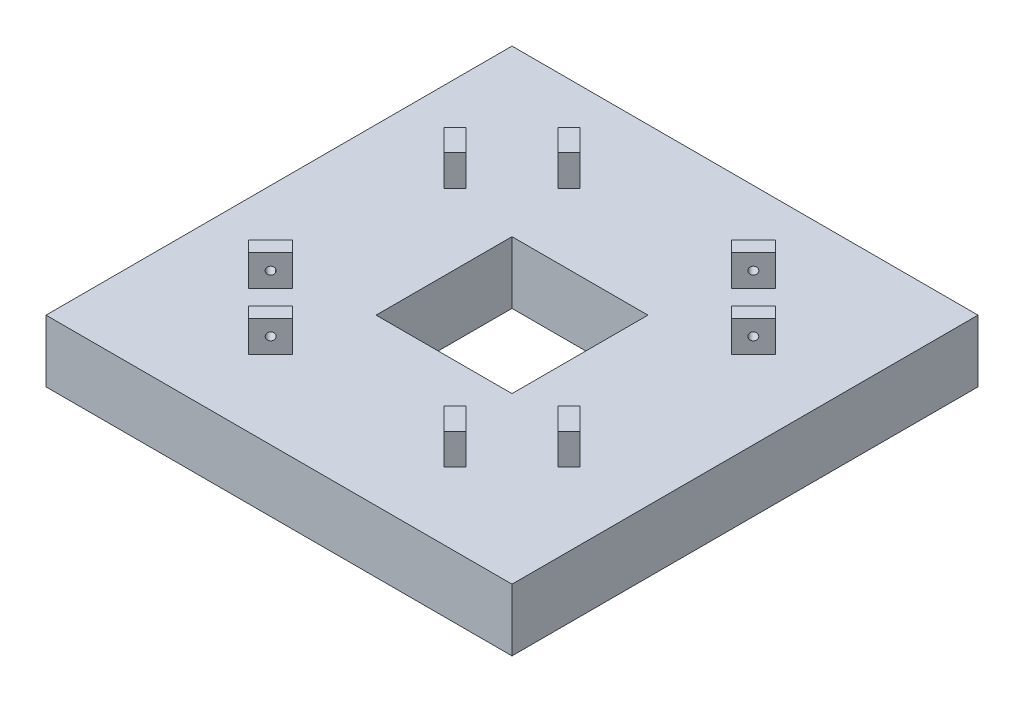
from build123d import *

# Parameters (mm, degrees)
SKETCH1_W           = 762
SKETCH1_H           = 762
BOSS_EXTRUDE1_DEPTH = 101.6
SKETCH3_W           = 222.25
SKETCH3_H           = 222.25
CUT_EXTRUDE1_DEPTH  = 549.310641881
BOSS_EXTRUDE2_DEPTH = 50.8
SKETCH5_R           = 6.35
CUT_EXTRUDE2_DEPTH  = 636.846628616
CIRPATTERN1_COUNT   = 4


with BuildPart() as part:
    # Sketch1 → Boss-Extrude1 (new body)
    with BuildSketch(Plane(origin=(0, 0, 0), x_dir=(1, 0, 0), z_dir=(0, 1, 0))):
        Rectangle(SKETCH1_W, SKETCH1_H)
    extrude(amount=BOSS_EXTRUDE1_DEPTH)

    # Sketch3 → Cut-Extrude1 (cut, through all)
    with BuildSketch(Plane(origin=(0, 101.6, 0), x_dir=(1, 0, 0), z_dir=(0, 1, 0))):
        Rectangle(SKETCH3_W, SKETCH3_H)
    extrude(amount=-CUT_EXTRUDE1_DEPTH, mode=Mode.SUBTRACT)

    # Sketch4 → Boss-Extrude2 (add)
    with BuildSketch(Plane(origin=(0, 101.6, 0), x_dir=(1, 0, 0), z_dir=(0, 1, 0))):
        Polygon((141.785512242, 216.876715762), (123.825, 234.837228004), (159.746024484, 270.758252488), (177.706536726, 252.797740246), align=None)
        Polygon((216.876715762, 141.785512242), (252.797740246, 177.706536726), (270.758252488, 159.746024484), (234.837228004, 123.825), align=None)
    boss_extrude2 = extrude(amount=BOSS_EXTRUDE2_DEPTH)

    # Sketch5 → Cut-Extrude2 (cut, through all)
    with BuildSketch(Plane(origin=(55.506114002, 0, 55.506114002), x_dir=(0.7071067811865475, 0, -0.7071067811865477), z_dir=(0.7071067811865477, 0, 0.7071067811865475))):
        with Locations((279.012493577, 127)):
            Circle(SKETCH5_R)
    cut_extrude2 = extrude(amount=-CUT_EXTRUDE2_DEPTH, mode=Mode.SUBTRACT)

    # CirPattern1: Boss-Extrude2, Cut-Extrude2 ×4 about axis
    cirpattern1_axis = Axis((0, 160.02, 0), (0, -1, 0))
    add([boss_extrude2.rotate(cirpattern1_axis, i * 360 / CIRPATTERN1_COUNT) for i in range(1, CIRPATTERN1_COUNT)])
    add([cut_extrude2.rotate(cirpattern1_axis, i * 360 / CIRPATTERN1_COUNT) for i in range(1, CIRPATTERN1_COUNT)], mode=Mode.SUBTRACT)


solid = part.part
